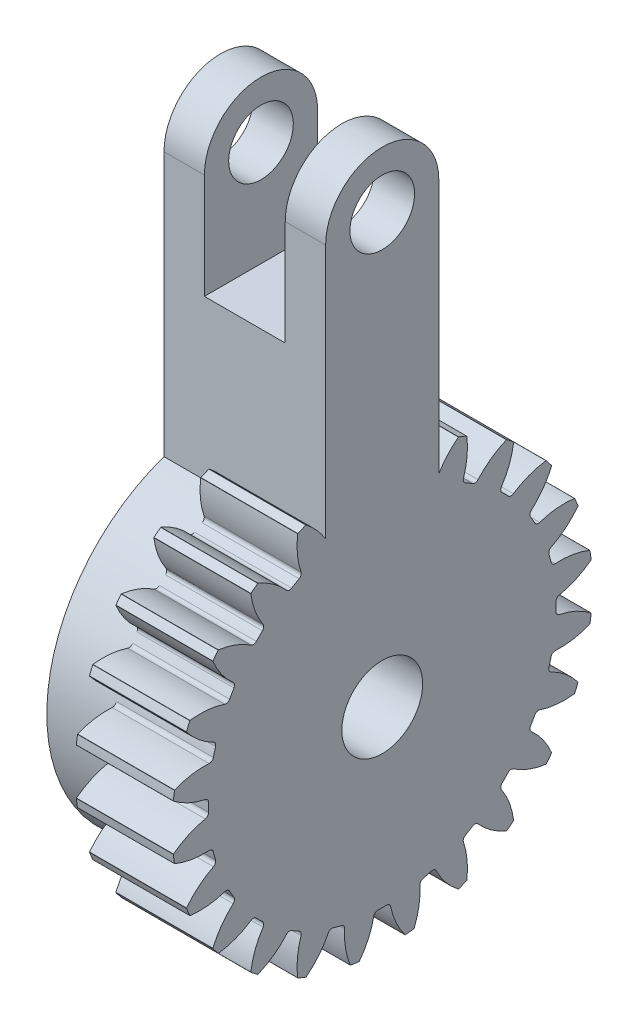
from build123d import *

# Parameters (mm, degrees)
BASPROSKE_W                = 6
BASPROSKE_H                = 13
TOOTHCUT_DEPTH             = 7
BREAKS_R                   = 0.02
ROOTFILLETS_R              = 0.251
TEETHCUTS_COUNT            = 24
BREAKS_OF_TEETHCUTS_R      = 0.02
ROOTFILLETS_OF_TEETHCUTS_R = 0.251
HUBNEAONESKE_R             = 10.749
HUBNEARONE_DEPTH           = 4
HUBNEABOTSKE_R             = 10.749
HUBNEARBOTH_DEPTH          = 4
BORSKE_R                   = 2.5
BORE_DEPTH                 = 50.001524
SKETCH_1_R                 = 9
EXTRUDE_1_DEPTH            = 4
SKETCH_2_R                 = 2.5
CUT_EXTRUDE_1_DEPTH        = 11.0000001
EXTRUDE_2_DEPTH            = 6
EXTRUDE_2_DEPTH_BACK       = 4
SKETCH_4_W                 = 5
SKETCH_4_H                 = 12
CUT_EXTRUDE_2_DEPTH        = 13.920803092
CUT_EXTRUDE_2_DEPTH_BACK   = 13.920803092
HOLE_WIZARD_M41_D          = 4
HOLE_WIZARD_M41_DEPTH      = 15
HOLE_WIZARD_M41_TIP        = 1.201721238


with BuildPart() as part:
    # BasProSke → Base-Revolve (revolve)
    with BuildSketch(Plane(origin=(0, 0, 0), x_dir=(1, 0, 0), z_dir=(0, 1, 0))):
        with Locations((3, 6.5)):
            Rectangle(BASPROSKE_W, BASPROSKE_H)
    revolve(axis=Axis((-10, 0, 0), (1, 0, 0)))

    # TooCutSke → ToothCut (cut, through all)
    with BuildSketch(Plane(origin=(0, 0, 0), x_dir=(0, 0, -1), z_dir=(1, 0, 0))):
        with BuildLine():
            ThreePointArc((0.483448384, 10.738122679), (0, 10.749), (-0.483448384, 10.738122679))
            ThreePointArc((-0.483448384, 10.738122679), (-0.821636462, 11.902754369), (-1.44092227, 12.945454344))
            ThreePointArc((-1.44092227, 12.945454344), (0, 13.0254), (1.44092227, 12.945454344))
            ThreePointArc((1.44092227, 12.945454344), (0.821636462, 11.902754369), (0.483448384, 10.738122679))
        make_face()
    toothcut = extrude(amount=TOOTHCUT_DEPTH, mode=Mode.SUBTRACT)

    # Breaks
    breaks_edges = [part.edges().sort_by_distance(p)[0] for p in [
        (3, 12.921919179, -1.422675204),
        (3, 12.921919179, 1.422675204),
    ]]
    fillet(breaks_edges, radius=BREAKS_R)

    # RootFillets
    rootfillets_edges = [part.edges().sort_by_distance(p)[0] for p in [
        (3, 10.738122679, -0.483448384),
        (3, 10.738122679, 0.483448384),
    ]]
    fillet(rootfillets_edges, radius=ROOTFILLETS_R)

    # TeethCuts: ToothCut ×24 about axis
    teethcuts_axis = Axis((0, 0, 0), (1, 0, 0))
    for i in range(1, TEETHCUTS_COUNT):
        add(toothcut.rotate(teethcuts_axis, i * 360 / TEETHCUTS_COUNT), mode=Mode.SUBTRACT)

    # Breaks of TeethCuts
    breaks_of_teethcuts_edges = [part.edges().sort_by_distance(p)[0] for p in [
        (3, 12.849830898, 1.970240061),
        (3, 12.113400022, 4.718637505),
        (3, 11.902047876, 5.228886722),
        (3, 10.479372673, 7.693032457),
        (3, 10.143159961, 8.131193393),
        (3, 8.131193393, 10.143159961),
        (3, 7.693032457, 10.479372673),
        (3, 5.228886722, 11.902047876),
        (3, 4.718637505, 12.113400022),
        (3, 1.970240061, 12.849830898),
        (3, 1.422675204, 12.921919179),
        (3, -1.422675204, 12.921919179),
        (3, -1.970240061, 12.849830898),
        (3, -4.718637505, 12.113400022),
        (3, -5.228886722, 11.902047876),
        (3, -7.693032457, 10.479372673),
        (3, -8.131193393, 10.143159961),
        (3, -10.143159961, 8.131193393),
        (3, -10.479372673, 7.693032457),
        (3, -11.902047876, 5.228886722),
        (3, -12.113400022, 4.718637505),
        (3, -12.849830898, 1.970240061),
        (3, -12.921919179, 1.422675204),
        (3, -12.921919179, -1.422675204),
        (3, -12.849830898, -1.970240061),
        (3, -12.113400022, -4.718637505),
        (3, -11.902047876, -5.228886722),
        (3, -10.479372673, -7.693032457),
        (3, -10.143159961, -8.131193393),
        (3, -8.131193393, -10.143159961),
        (3, -7.693032457, -10.479372673),
        (3, -5.228886722, -11.902047876),
        (3, -4.718637505, -12.113400022),
        (3, -1.970240061, -12.849830898),
        (3, -1.422675204, -12.921919179),
        (3, 1.422675204, -12.921919179),
        (3, 1.970240061, -12.849830898),
        (3, 4.718637505, -12.113400022),
        (3, 5.228886722, -11.902047876),
        (3, 7.693032457, -10.479372673),
        (3, 8.131193393, -10.143159961),
        (3, 10.143159961, -8.131193393),
        (3, 10.479372673, -7.693032457),
        (3, 11.902047876, -5.228886722),
        (3, 12.113400022, -4.718637505),
        (3, 12.849830898, -1.970240061),
    ]]
    fillet(breaks_of_teethcuts_edges, radius=BREAKS_OF_TEETHCUTS_R)

    # RootFillets of TeethCuts
    rootfillets_of_teethcuts_edges = [part.edges().sort_by_distance(p)[0] for p in [
        (3, 10.49735567, 2.312255378),
        (3, 10.247104372, 3.246205938),
        (3, 9.541211221, 4.950382757),
        (3, 9.057762836, 5.787739922),
        (3, 7.934848994, 7.251149732),
        (3, 7.251149732, 7.934848994),
        (3, 5.787739922, 9.057762836),
        (3, 4.950382757, 9.541211221),
        (3, 3.246205938, 10.247104372),
        (3, 2.312255378, 10.49735567),
        (3, 0.483448384, 10.738122679),
        (3, -0.483448384, 10.738122679),
        (3, -2.312255378, 10.49735567),
        (3, -3.246205938, 10.247104372),
        (3, -4.950382757, 9.541211221),
        (3, -5.787739922, 9.057762836),
        (3, -7.251149732, 7.934848994),
        (3, -7.934848994, 7.251149732),
        (3, -9.057762836, 5.787739922),
        (3, -9.541211221, 4.950382757),
        (3, -10.247104372, 3.246205938),
        (3, -10.49735567, 2.312255378),
        (3, -10.738122679, 0.483448384),
        (3, -10.738122679, -0.483448384),
        (3, -10.49735567, -2.312255378),
        (3, -10.247104372, -3.246205938),
        (3, -9.541211221, -4.950382757),
        (3, -9.057762836, -5.787739922),
        (3, -7.934848994, -7.251149732),
        (3, -7.251149732, -7.934848994),
        (3, -5.787739922, -9.057762836),
        (3, -4.950382757, -9.541211221),
        (3, -3.246205938, -10.247104372),
        (3, -2.312255378, -10.49735567),
        (3, -0.483448384, -10.738122679),
        (3, 0.483448384, -10.738122679),
        (3, 2.312255378, -10.49735567),
        (3, 3.246205938, -10.247104372),
        (3, 4.950382757, -9.541211221),
        (3, 5.787739922, -9.057762836),
        (3, 7.251149732, -7.934848994),
        (3, 7.934848994, -7.251149732),
        (3, 9.057762836, -5.787739922),
        (3, 9.541211221, -4.950382757),
        (3, 10.247104372, -3.246205938),
        (3, 10.49735567, -2.312255378),
    ]]
    fillet(rootfillets_of_teethcuts_edges, radius=ROOTFILLETS_OF_TEETHCUTS_R)

    # HubNeaOneSke → HubNearOne (add)
    with BuildSketch(Plane.ZY):
        Circle(HUBNEAONESKE_R)
    extrude(amount=HUBNEARONE_DEPTH)

    # HubNeaBotSke → HubNearBoth (add)
    with BuildSketch(Plane.ZY):
        Circle(HUBNEABOTSKE_R)
    extrude(amount=HUBNEARBOTH_DEPTH)

    # BorSke → Bore (cut, symmetric)
    with BuildSketch(Plane(origin=(0, 0, 0), x_dir=(0, 0, -1), z_dir=(1, 0, 0))):
        Circle(BORSKE_R)
    extrude(amount=BORE_DEPTH, both=True, mode=Mode.SUBTRACT)

    # Эскиз1 → Бобышка-Вытянуть1 (add)
    with BuildSketch(Plane.ZY):
        Circle(SKETCH_1_R)
    extrude(amount=EXTRUDE_1_DEPTH)

    # Эскиз2 → Вырез-Вытянуть1 (cut, through all)
    with BuildSketch(Plane.ZY.offset(4)):
        Circle(SKETCH_2_R)
    extrude(amount=-CUT_EXTRUDE_1_DEPTH, mode=Mode.SUBTRACT)

    # Эскиз3 → Бобышка-Вытянуть2 (add, two sides)
    with BuildSketch(Plane(origin=(0, 0, 0), x_dir=(0, 0, -1), z_dir=(1, 0, 0))) as extrude_2_sk:
        with BuildLine():
            Line((-3.5, 26.5), (-3.5, 7))
            Line((-3.5, 7), (3.5, 7))
            Line((3.5, 7), (3.5, 26.5))
            ThreePointArc((3.5, 26.5), (0, 30), (-3.5, 26.5))
        make_face()
    extrude(amount=EXTRUDE_2_DEPTH)
    extrude(extrude_2_sk.sketch, amount=-EXTRUDE_2_DEPTH_BACK)

    # Эскиз4 → Вырез-Вытянуть2 (cut, two sides)
    with BuildSketch(Plane.XY) as cut_extrude_2_sk:
        with Locations((1, 26)):
            Rectangle(SKETCH_4_W, SKETCH_4_H)
    extrude(amount=CUT_EXTRUDE_2_DEPTH, mode=Mode.SUBTRACT)
    extrude(cut_extrude_2_sk.sketch, amount=-CUT_EXTRUDE_2_DEPTH_BACK, mode=Mode.SUBTRACT)

    # Отверстие с зазором M41
    with Locations(Plane(origin=(6, 0, 0), x_dir=(0, 0, -1), z_dir=(1, 0, 0))):
        with Locations((0, 26.5)):
            Hole(HOLE_WIZARD_M41_D / 2, depth=HOLE_WIZARD_M41_DEPTH)
            with Locations((0, 0, -(HOLE_WIZARD_M41_DEPTH + HOLE_WIZARD_M41_TIP / 2))):  # 118° drill point
                Cone(0, HOLE_WIZARD_M41_D / 2, HOLE_WIZARD_M41_TIP, mode=Mode.SUBTRACT)


solid = part.part
